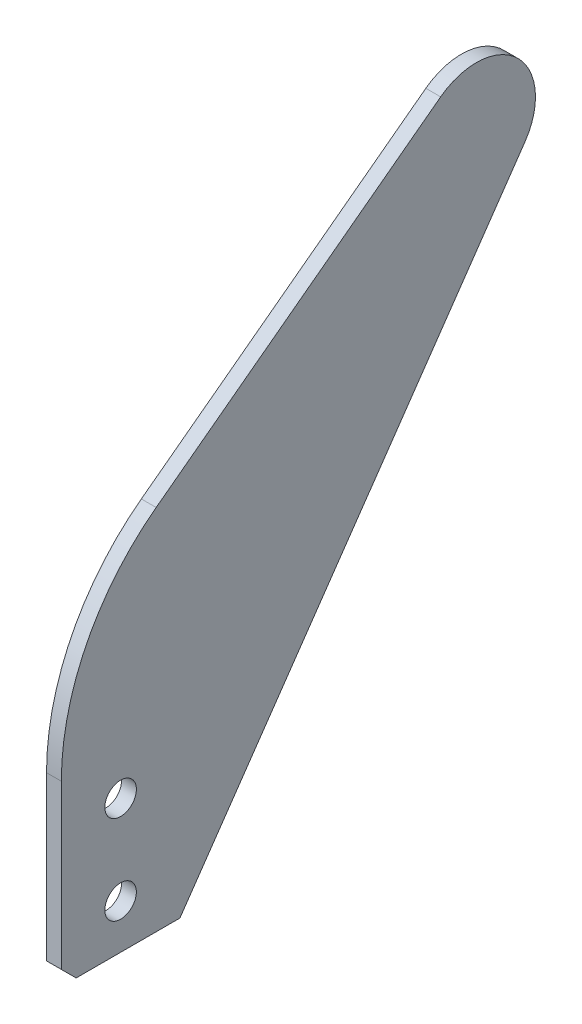
from build123d import *

# Parameters (mm, degrees)
SKETCH1_R           = 3.3782
BOSS_EXTRUDE1_DEPTH = 3.175
CHAMFER1_SIZE       = 3.175


with BuildPart() as part:
    # Sketch1 → Boss-Extrude1 (new body)
    with BuildSketch(Plane(origin=(0, 0, 0), x_dir=(0, 0, -1), z_dir=(1, 0, 0))):
        with BuildLine():
            Line((0, 0), (0, 38.1))
            ThreePointArc((0, 38.1), (5.363098697, 60.818450651), (20.32, 78.74))
            Line((20.32, 78.74), (81.28, 124.46))
            ThreePointArc((81.28, 124.46), (97.702892705, 123.454183744), (99.350249741, 107.083194588))
            Line((99.350249741, 107.083194588), (25.4, 0))
            Line((25.4, 0), (0, 0))
        make_face()
        with Locations((12.7, 9.525)):
            Circle(SKETCH1_R, mode=Mode.SUBTRACT)
        with Locations((12.7, 28.575)):
            Circle(SKETCH1_R, mode=Mode.SUBTRACT)
    extrude(amount=BOSS_EXTRUDE1_DEPTH)

    # Chamfer1
    chamfer1_edges = [part.edges().sort_by_distance(p)[0] for p in [
        (1.5875, 0, 0),
    ]]
    chamfer(chamfer1_edges, length=CHAMFER1_SIZE)


solid = part.part
